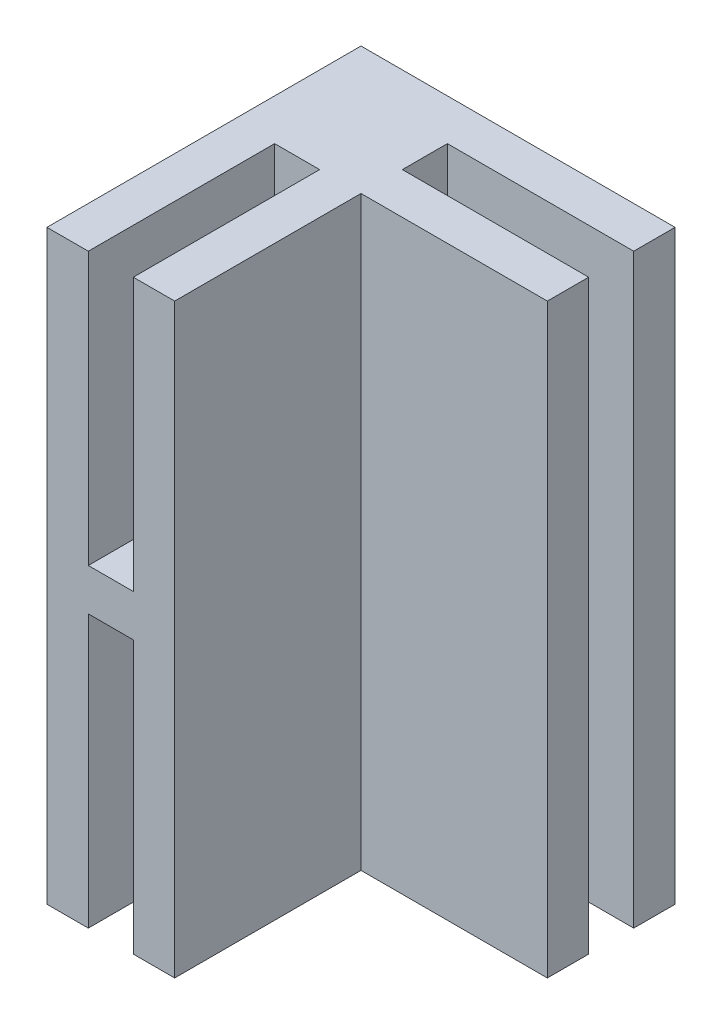
from build123d import *

# Parameters (mm, degrees)
ESQUISSE1_W             = 30
ESQUISSE1_H             = 30
BOSS_EXTRU_1_DEPTH      = 56
ESQUISSE2_W             = 17.8
ESQUISSE2_H             = 4.3
ESQUISSE2_H_2           = 17.8
ENL_V_MAT_EXTRU_1_DEPTH = 57
ESQUISSE3_W             = 4.3
ESQUISSE3_H             = 17.8
ENL_V_MAT_EXTRU_2_DEPTH = 26
ESQUISSE6_W             = 4.3
ESQUISSE6_H             = 17.8
ENL_V_MAT_EXTRU_4_DEPTH = 26


with BuildPart() as part:
    # Esquisse1 → Boss.-Extru.1 (new body)
    with BuildSketch(Plane(origin=(0, 0, 0), x_dir=(1, 0, 0), z_dir=(0, 1, 0))):
        with Locations((3.620689655, -5.615763547)):
            Rectangle(ESQUISSE1_W, ESQUISSE1_H)
    extrude(amount=BOSS_EXTRU_1_DEPTH)

    # Esquisse2 → Enlèv. mat.-Extru.1 (cut, through all)
    with BuildSketch(Plane.XZ):
        with Locations((9.720689655, -3.284236453)):
            Rectangle(ESQUISSE2_W, ESQUISSE2_H)
        with Locations((9.720689655, 11.715763547)):
            Rectangle(ESQUISSE2_W, ESQUISSE2_H_2)
    extrude(amount=-ENL_V_MAT_EXTRU_1_DEPTH, mode=Mode.SUBTRACT)

    # Esquisse3 → Enlèv. mat.-Extru.2 (cut)
    with BuildSketch(Plane.XZ):
        with Locations((-5.279310345, 11.715763547)):
            Rectangle(ESQUISSE3_W, ESQUISSE3_H)
    extrude(amount=-ENL_V_MAT_EXTRU_2_DEPTH, mode=Mode.SUBTRACT)

    # Esquisse6 → Enlèv. mat.-Extru.4 (cut)
    with BuildSketch(Plane(origin=(0, 56, 0), x_dir=(1, 0, 0), z_dir=(0, 1, 0))):
        with Locations((-5.279310345, -11.715763547)):
            Rectangle(ESQUISSE6_W, ESQUISSE6_H)
    extrude(amount=-ENL_V_MAT_EXTRU_4_DEPTH, mode=Mode.SUBTRACT)


solid = part.part
